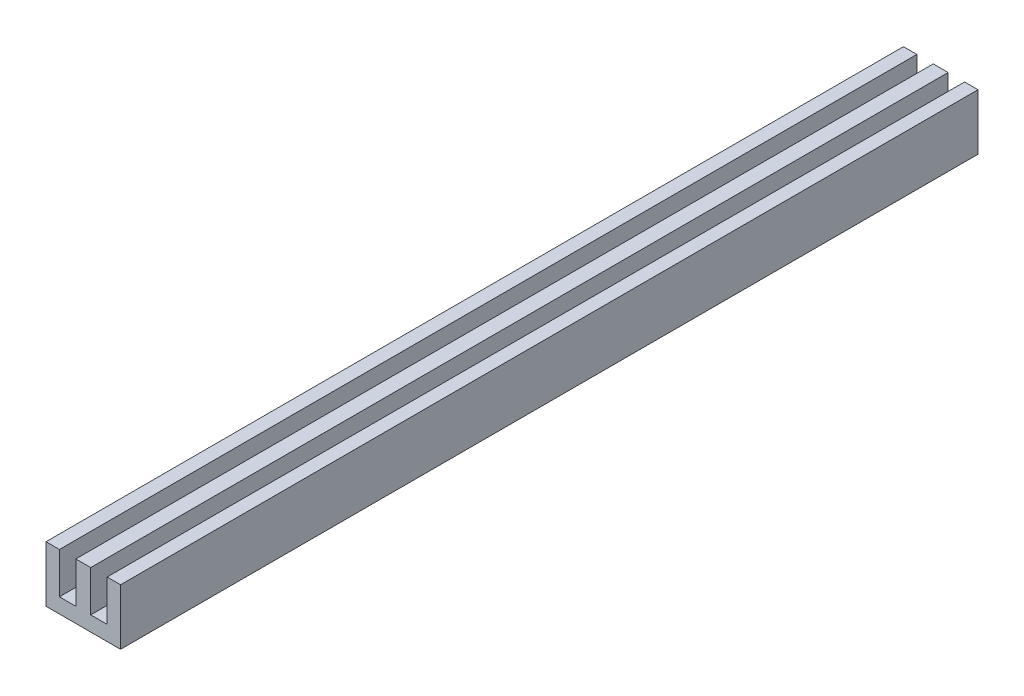
from build123d import *

# Parameters (mm, degrees)
ESBO_O1_W                = 1.8
ESBO_O1_H                = 5.5
RESSALTO_EXTRUS_O1_DEPTH = 115


with BuildPart() as part:
    # Esboço1 → Ressalto-extrusão1 (new body)
    with BuildSketch(Plane.XY):
        with Locations((-8.1, 1.25)):
            Rectangle(ESBO_O1_W, ESBO_O1_H)
        Polygon((-5, -1.198132677), (-5, -1.5), (-4, -1.5), (-4, 4), (-5, 4), align=None)
        Polygon((-4, 4), (-4, -1.5), (-3, -1.5), (-3, -1.198132677), (-3, 4), align=None)
        Polygon((-4, -1.5), (-5, -1.5), (-5.301867323, -1.5), (-6.898310084, -1.5), (-7.2, -1.5), (-9, -1.5), (-9, -3.5), (1, -3.5), (1, -1.5), (-0.8, -1.5), (-1.101689916, -1.5), (-2.698132677, -1.5), (-3, -1.5), align=None)
        with Locations((0.1, 1.25)):
            Rectangle(ESBO_O1_W, ESBO_O1_H)
    extrude(amount=RESSALTO_EXTRUS_O1_DEPTH)


solid = part.part
